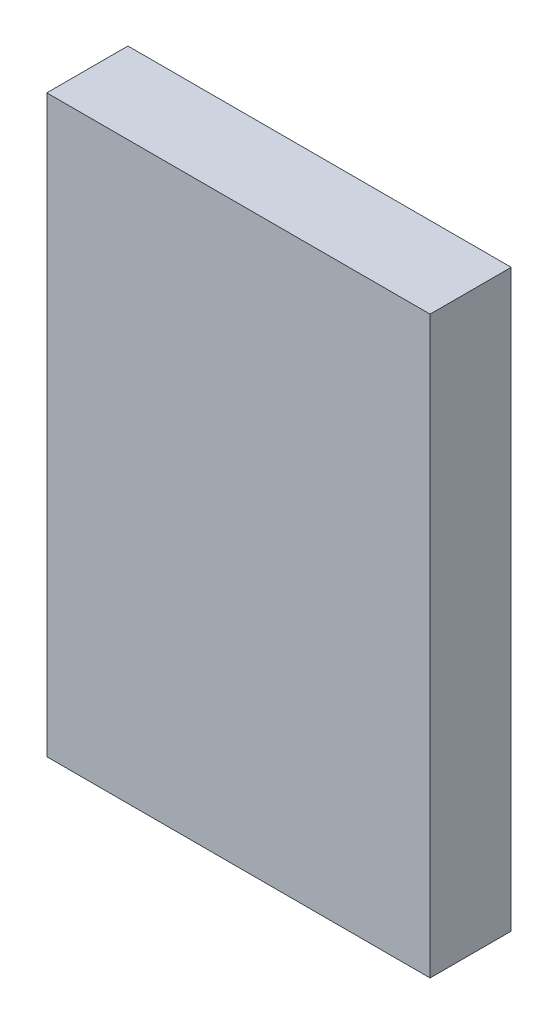
from build123d import *

# Parameters (mm, degrees)
SKETCH1_W           = 30
SKETCH1_H           = 45
BOSS_EXTRUDE1_DEPTH = 6.35


with BuildPart() as part:
    # Sketch1 → Boss-Extrude1 (new body)
    with BuildSketch(Plane.XY):
        with Locations((15, 22.5)):
            Rectangle(SKETCH1_W, SKETCH1_H)
    extrude(amount=BOSS_EXTRUDE1_DEPTH)


solid = part.part
